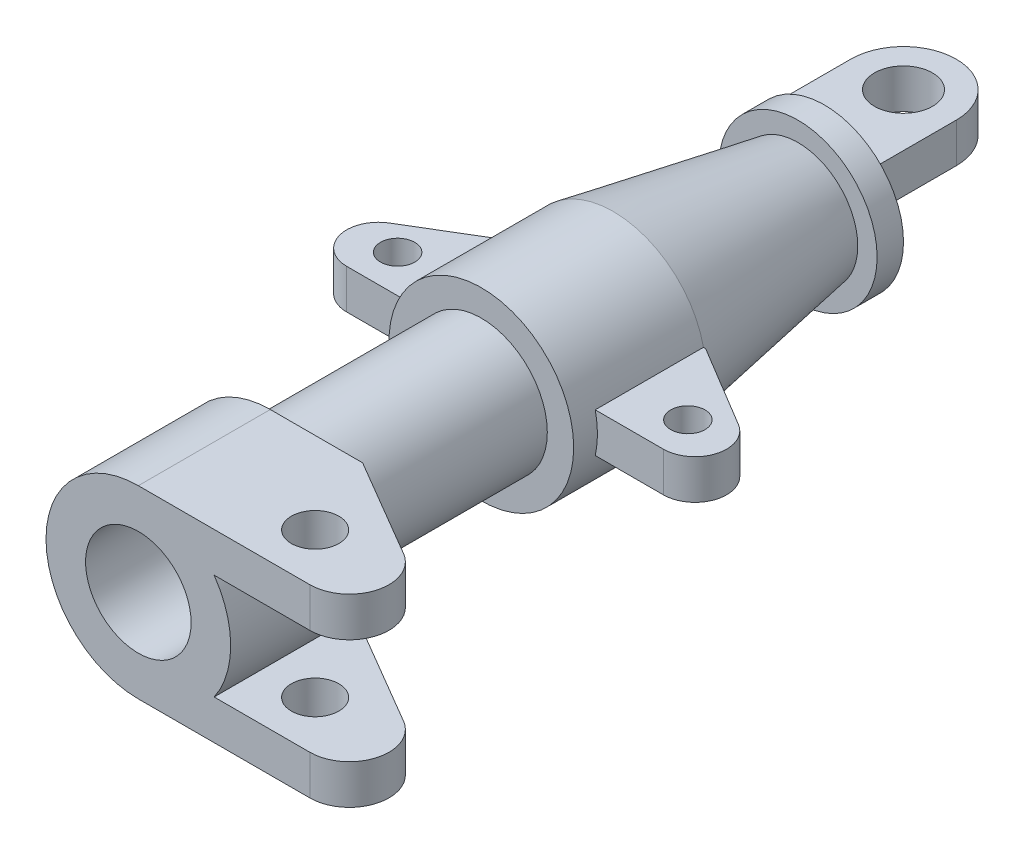
from build123d import *

# Parameters (mm, degrees)
SKETCH2_R                = 6.5
SKETCH2_W                = 10
SKETCH2_H                = 41.021116242
BOSS_EXTRUDE1_DEPTH      = 7.5
SKETCH3_R                = 9
BOSS_EXTRUDE2_DEPTH      = 35
BOSS_EXTRUDE2_DEPTH_BACK = 35
BOSS_EXTRUDE3_START      = -10.090847
SKETCH4_W                = 24.58727528
SKETCH4_H                = 50
BOSS_EXTRUDE3_DEPTH      = 10.090847
CUT_EXTRUDE1_DEPTH       = 51
SKETCH6_R                = 11
BOSS_EXTRUDE4_DEPTH      = 20
SKETCH6_3_R              = 11
CUT_EXTRUDE2_DEPTH       = 5


with BuildPart() as part:
    # Sketch1 → Revolve1 (revolve)
    with BuildSketch(Plane(origin=(0, 0, 0), x_dir=(1, 0, 0), z_dir=(0, 1, 0))):
        Polygon((-35, 0), (-20, 0), (-20, 235), (0, 235), (0, 260), (-30, 260), (-30, 250), (-22.65711135, 250), (-35, 180), (-35, 130), (-25, 130), (-25, 50), (-35, 50), align=None)
    revolve(axis=Axis((0, 0, 0), (0, 0, -1)))

    # Sketch2 → Boss-Extrude1 (add, symmetric)
    with BuildSketch(Plane(origin=(0, 0, 0), x_dir=(1, 0, 0), z_dir=(0, 1, 0))):
        with BuildLine():
            ThreePointArc((-60, 138.978883758), (-71.563565439, 147.772023245), (-66.180456899, 161.264891366))
            Line((-66.180456899, 161.264891366), (-35, 180))
            Line((-35, 180), (-35, 138.978883758))
            Line((-35, 138.978883758), (-60, 138.978883758))
        make_face()
        with Locations((-55, 153.268883758)):
            Circle(SKETCH2_R, mode=Mode.SUBTRACT)
        with Locations((-30, 159.489441879)):
            Rectangle(SKETCH2_W, SKETCH2_H)
        with Locations((30, 159.489441879)):
            Rectangle(SKETCH2_W, SKETCH2_H)
        with BuildLine():
            Line((35, 138.978883758), (60, 138.978883758))
            ThreePointArc((60, 138.978883758), (71.563565439, 147.772023245), (66.180456899, 161.264891366))
            Line((66.180456899, 161.264891366), (35, 180))
            Line((35, 180), (35, 138.978883758))
        make_face()
        with Locations((55, 153.268883758)):
            Circle(SKETCH2_R, mode=Mode.SUBTRACT)
    extrude(amount=BOSS_EXTRUDE1_DEPTH, both=True)

    # Sketch3 → Boss-Extrude2 (add, two sides)
    with BuildSketch(Plane(origin=(0, 0, 0), x_dir=(1, 0, 0), z_dir=(0, 1, 0))) as boss_extrude2_sk:
        with BuildLine():
            Line((35, 0), (65, 0))
            ThreePointArc((65, 0), (79.474933129, 11.066005733), (72.592573861, 27.93649188))
            Line((72.592573861, 27.93649188), (35, 50))
            Line((35, 50), (24.58727528, 50))
            Line((24.58727528, 50), (24.58727528, 0))
            Line((24.58727528, 0), (35, 0))
        make_face()
        with Locations((48, 19)):
            Circle(SKETCH3_R, mode=Mode.SUBTRACT)
    extrude(amount=BOSS_EXTRUDE2_DEPTH)
    extrude(boss_extrude2_sk.sketch, amount=-BOSS_EXTRUDE2_DEPTH_BACK)

    # Sketch4 → Boss-Extrude3 (add)
    with BuildSketch(Plane(origin=(0, 35, 0), x_dir=(1, 0, 0), z_dir=(0, 1, 0)).offset(BOSS_EXTRUDE3_START)):
        with Locations((12.29363764, 25)):
            Rectangle(SKETCH4_W, SKETCH4_H)
    boss_extrude3 = extrude(amount=BOSS_EXTRUDE3_DEPTH)

    # Mirror1: Boss-Extrude3 across plane
    add(boss_extrude3.mirror(Plane.ZX))

    # Sketch5 → Cut-Extrude1 (cut, through all)
    with BuildSketch(Plane(origin=(0, 0, -50), x_dir=(-1, 0, 0), z_dir=(0, 0, -1))):
        Polygon((-90.173846019, 20), (-90.173846019, -20), (-35, -20), (-35, -3.8e-08), (-35, 20), align=None)
        with BuildLine():
            Line((-35, 20), (-35, -3.8e-08))
            ThreePointArc((-35, -3.8e-08), (-33.393850212, 10.480971713), (-28.722813233, 20))
            Line((-28.722813233, 20), (-35, 20))
        make_face()
        with BuildLine():
            Line((-35, -3.8e-08), (-35, -20))
            Line((-35, -20), (-28.722813233, -20))
            ThreePointArc((-28.722813233, -20), (-33.3938502, -10.480971749), (-35, -3.8e-08))
        make_face()
    extrude(amount=-CUT_EXTRUDE1_DEPTH, mode=Mode.SUBTRACT)

    # Sketch6 → Boss-Extrude4 (add)
    with BuildSketch(Plane(origin=(0, 0, 0), x_dir=(0, 0, -1), z_dir=(0, 1, 0))):
        with BuildLine():
            Line((260, 20), (260, -20))
            Line((260, -20), (290, -20))
            ThreePointArc((290, -20), (310, 0), (290, 20))
            Line((290, 20), (260, 20))
        make_face()
        with Locations((290, 0)):
            Circle(SKETCH6_R, mode=Mode.SUBTRACT)
    extrude(amount=BOSS_EXTRUDE4_DEPTH)

    # Sketch6_3 → Cut-Extrude2 (cut)
    with BuildSketch(Plane(origin=(0, 0, 0), x_dir=(0, 0, -1), z_dir=(0, 1, 0))):
        with BuildLine():
            Line((260, 20), (260, -20))
            Line((260, -20), (290, -20))
            ThreePointArc((290, -20), (310, 0), (290, 20))
            Line((290, 20), (260, 20))
        make_face()
        with Locations((290, 0)):
            Circle(SKETCH6_3_R, mode=Mode.SUBTRACT)
    extrude(amount=CUT_EXTRUDE2_DEPTH, mode=Mode.SUBTRACT)


solid = part.part
